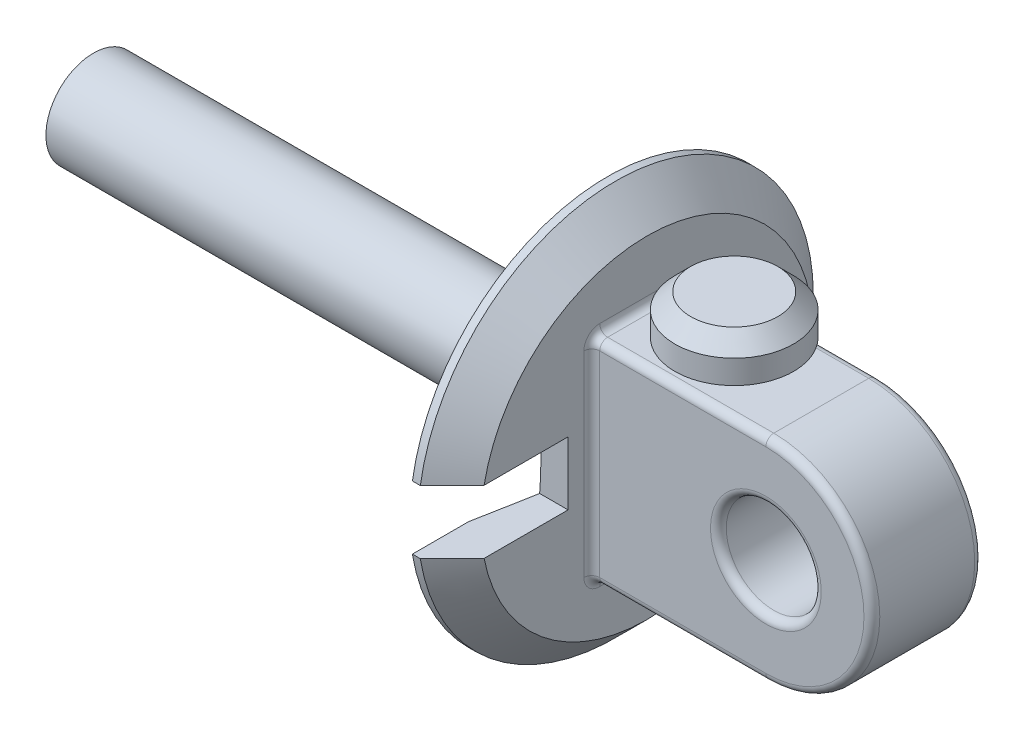
from build123d import *

# Parameters (mm, degrees)
SKETCH1_R               = 6
BOSS_EXTRUDE3_DEPTH     = 7
SKETCH6_R               = 25
BOSS_EXTRUDE4_DEPTH     = 5
CHAMFER1_SIZE           = 4
SKETCH8_R               = 6
BOSS_EXTRUDE5_DEPTH     = 70
SKETCH9_R               = 3
BOSS_EXTRUDE6_DEPTH     = 2
SKETCH10_R              = 7.5
BOSS_EXTRUDE7_DEPTH     = 5
CHAMFER2_SIZE           = 2
SKETCH13_W              = 30
SKETCH13_H              = 8
CUT_EXTRUDE1_DEPTH      = 66
CUT_EXTRUDE1_DEPTH_BACK = 41.4
FILLET1_R               = 1


with BuildPart() as part:
    # Sketch1 → Boss-Extrude3 (new body, symmetric)
    with BuildSketch(Plane.XY):
        with BuildLine():
            Line((0, 13.4), (-22, 13.4))
            Line((-22, 13.4), (-22, -13.4))
            Line((-22, -13.4), (0, -13.4))
            ThreePointArc((0, -13.4), (13.4, 0), (0, 13.4))
        make_face()
        Circle(SKETCH1_R, mode=Mode.SUBTRACT)
    extrude(amount=BOSS_EXTRUDE3_DEPTH, both=True)

    # Sketch6 → Boss-Extrude4 (add)
    with BuildSketch(Plane.ZY.offset(22)):
        Circle(SKETCH6_R)
    extrude(amount=BOSS_EXTRUDE4_DEPTH)

    # Sketch7 → Cut-Revolve2 (revolve, cut)
    with BuildSketch(Plane.XY):
        Polygon((-27, 0), (-23.5, 0), (-27, -18), align=None)
    revolve(axis=Axis((-27, 0, 0), (1, 0, 0)), mode=Mode.SUBTRACT)

    # Chamfer1
    chamfer1_edges = [part.edges().sort_by_distance(p)[0] for p in [
        (-22, 0, -25),
    ]]
    chamfer(chamfer1_edges, length=CHAMFER1_SIZE)

    # Sketch8 → Boss-Extrude5 (add)
    with BuildSketch(Plane(origin=(-22, 0, 0), x_dir=(0, 0, -1), z_dir=(1, 0, 0))):
        Circle(SKETCH8_R)
    extrude(amount=-BOSS_EXTRUDE5_DEPTH)

    # Sketch9 → Boss-Extrude6 (add)
    with BuildSketch(Plane(origin=(0, 13.4, 0), x_dir=(1, 0, 0), z_dir=(0, 1, 0))):
        with Locations((-11, 0)):
            Circle(SKETCH9_R)
    extrude(amount=BOSS_EXTRUDE6_DEPTH)

    # Sketch10 → Boss-Extrude7 (add)
    with BuildSketch(Plane(origin=(0, 15.4, 0), x_dir=(1, 0, 0), z_dir=(0, 1, 0))):
        with Locations((-11, 0)):
            Circle(SKETCH10_R)
    extrude(amount=BOSS_EXTRUDE7_DEPTH)

    # Chamfer2
    chamfer2_edges = [part.edges().sort_by_distance(p)[0] for p in [
        (-18.5, 20.4, 0),
    ]]
    chamfer(chamfer2_edges, length=CHAMFER2_SIZE)

    # Sketch13 → Cut-Extrude1 (cut, two sides)
    with BuildSketch(Plane.ZY.offset(27)) as cut_extrude1_sk:
        with Locations((25, 0)):
            Rectangle(SKETCH13_W, SKETCH13_H)
    extrude(amount=CUT_EXTRUDE1_DEPTH, mode=Mode.SUBTRACT)
    extrude(cut_extrude1_sk.sketch, amount=-CUT_EXTRUDE1_DEPTH_BACK, mode=Mode.SUBTRACT)

    # Fillet1
    fillet1_edges = [part.edges().sort_by_distance(p)[0] for p in [
        (-6, 0, -7),
        (-6, 0, 7),
        (-22, 0, 7),
        (-11, -13.4, 7),
        (13.4, 0, 7),
        (-11, -13.4, -7),
        (-22, 0, -7),
        (-11, 13.4, -7),
        (13.4, 0, -7),
        (-22, -13.4, 0),
        (-22, 13.4, 0),
        (-11, 13.4, 7),
    ]]
    fillet(fillet1_edges, radius=FILLET1_R)


solid = part.part
